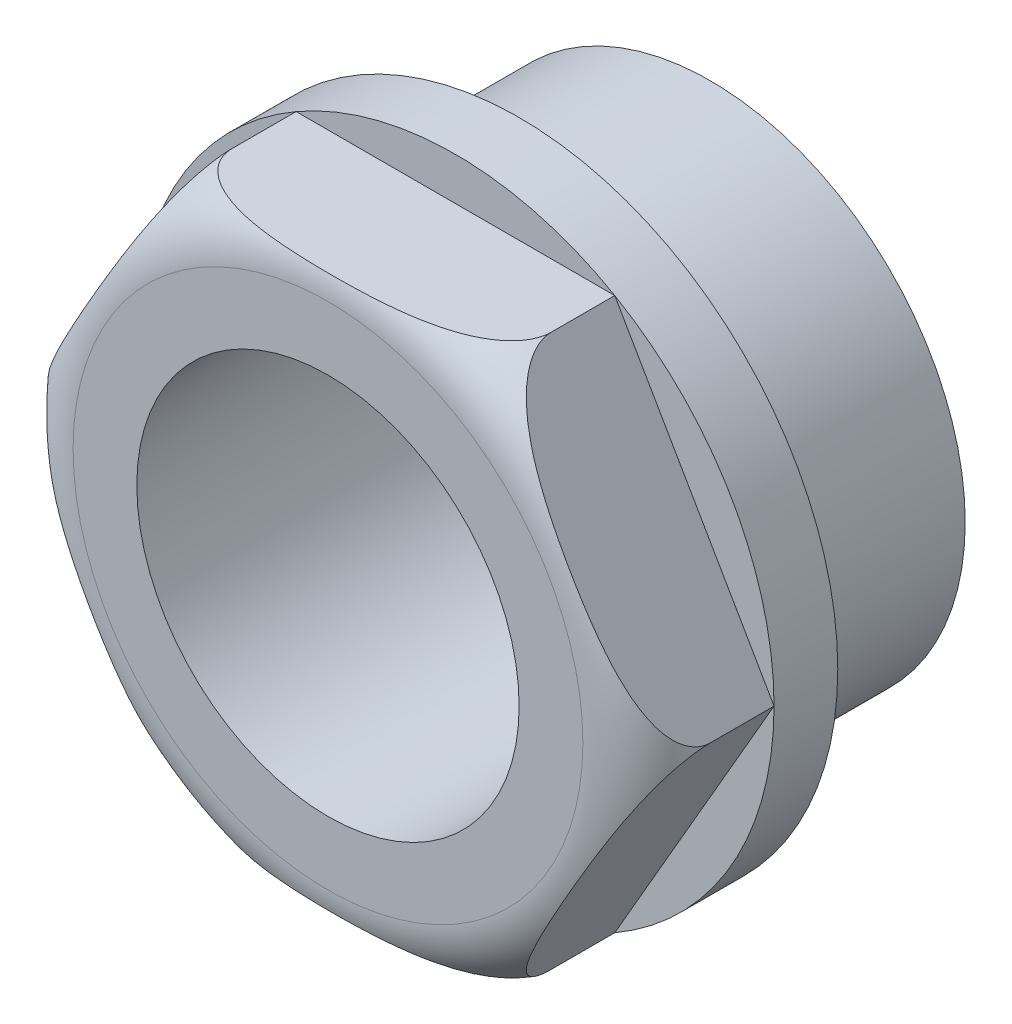
from build123d import *

# Parameters (mm, degrees)
SKETCH_1_R          = 8
EXTRUDE_1_DEPTH     = 6
SKETCH_2_R          = 10
EXTRUDE_2_DEPTH     = 6
FILLET_1_R          = 2
SKETCH_3_OUTSIDE_W  = 28.144
SKETCH_3_OUTSIDE_H  = 28.144
CUT_EXTRUDE_1_DEPTH = 4
SKETCH_4_R          = 6
CUT_EXTRUDE_2_DEPTH = 12


with BuildPart() as part:
    # 草图1 → 凸台-拉伸1 (new body)
    with BuildSketch(Plane.XY):
        Circle(SKETCH_1_R)
    extrude(amount=EXTRUDE_1_DEPTH)

    # 草图2 → 凸台-拉伸2 (add)
    with BuildSketch(Plane.XY.offset(6)):
        Circle(SKETCH_2_R)
    extrude(amount=EXTRUDE_2_DEPTH)

    # 圆角1
    fillet_1_edges = [part.edges().sort_by_distance(p)[0] for p in [
        (-10, 0, 12),
    ]]
    fillet(fillet_1_edges, radius=FILLET_1_R)

    # 草图3 outside → 切除-拉伸1 (cut)
    with BuildSketch(Plane.XY.offset(12)):
        Rectangle(SKETCH_3_OUTSIDE_W, SKETCH_3_OUTSIDE_H)
        Polygon((10, 0), (5, 8.660254038), (-5, 8.660254038), (-10, 0), (-5, -8.660254038), (5, -8.660254038), align=None, mode=Mode.SUBTRACT)
    extrude(amount=-CUT_EXTRUDE_1_DEPTH, mode=Mode.SUBTRACT)

    # 草图4 → 切除-拉伸2 (cut)
    with BuildSketch(Plane(origin=(0, 0, 0), x_dir=(-1, 0, 0), z_dir=(0, 0, -1))):
        Circle(SKETCH_4_R)
    extrude(amount=-CUT_EXTRUDE_2_DEPTH, mode=Mode.SUBTRACT)


solid = part.part
